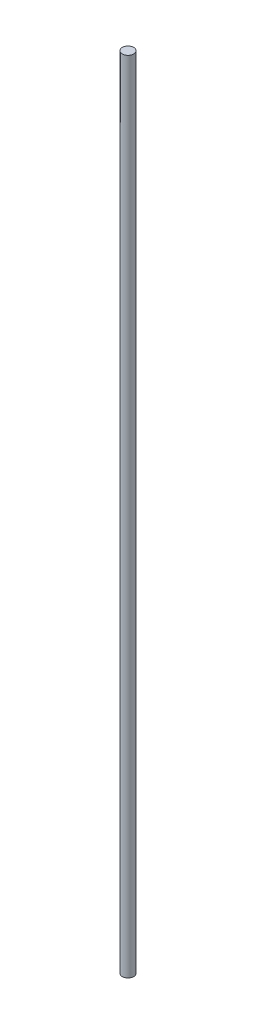
from build123d import *

# Parameters (mm, degrees)
SKETCH_1_R      = 12.5
EXTRUDE_1_DEPTH = 1750


with BuildPart() as part:
    # 草图1 → 凸台-拉伸1 (new body)
    with BuildSketch(Plane(origin=(0, 0, 0), x_dir=(1, 0, 0), z_dir=(0, 1, 0))):
        Circle(SKETCH_1_R)
    extrude(amount=EXTRUDE_1_DEPTH)


solid = part.part
